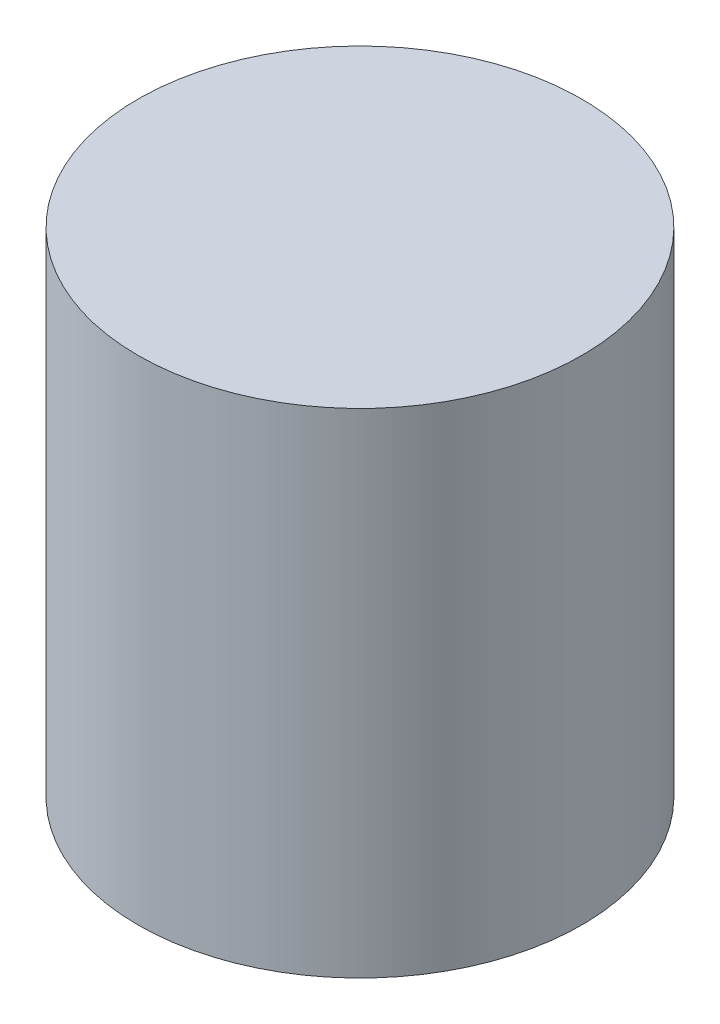
from build123d import *

# Parameters (mm, degrees)
SKETCH1_R           = 2.25
BOSS_EXTRUDE1_DEPTH = 5


with BuildPart() as part:
    # Sketch1 → Boss-Extrude1 (new body)
    with BuildSketch(Plane(origin=(0, 0, 0), x_dir=(1, 0, 0), z_dir=(0, 1, 0))):
        Circle(SKETCH1_R)
    extrude(amount=BOSS_EXTRUDE1_DEPTH)


solid = part.part
